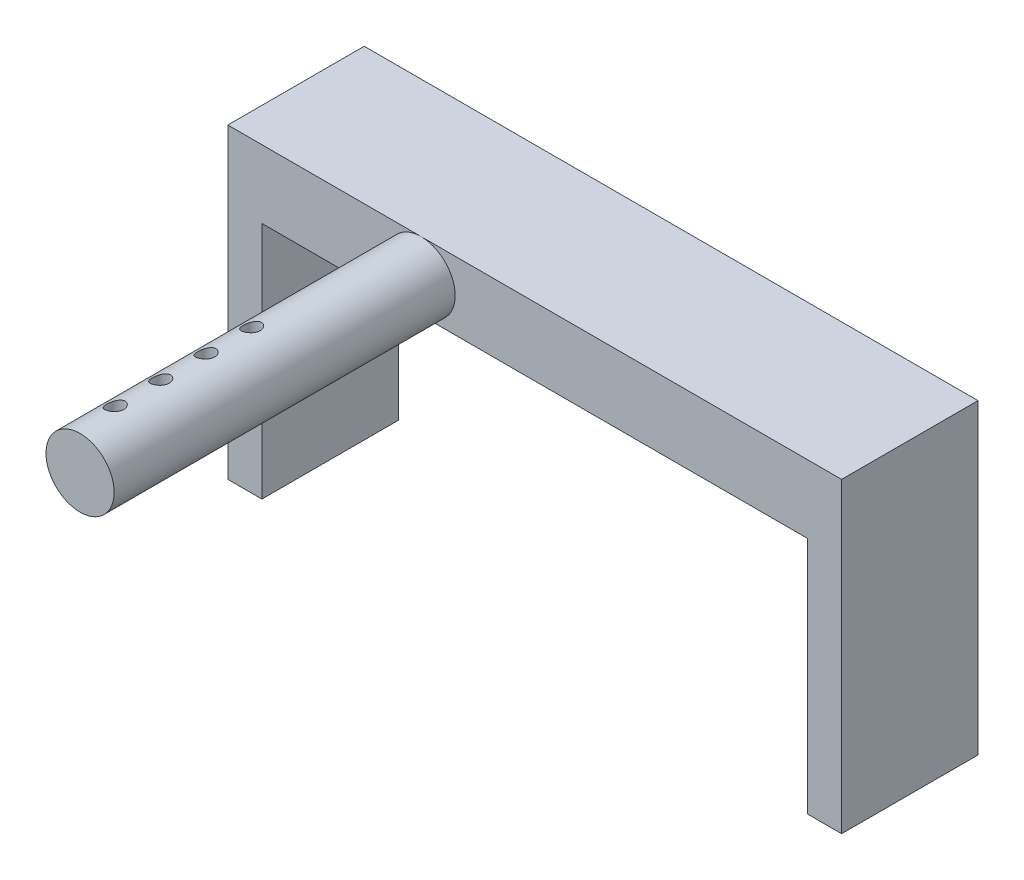
from build123d import *

# Parameters (mm, degrees)
BOSS_EXTRUDE1_DEPTH = 12
SKETCH2_R           = 3
BOSS_EXTRUDE2_DEPTH = 30
CUT_EXTRUDE1_REACH  = 29
SKETCH3_R           = 0.75
SKETCH4_R           = 1.45
CUT_EXTRUDE2_DEPTH  = 5


with BuildPart() as part:
    # Sketch1 → Boss-Extrude1 (new body)
    with BuildSketch(Plane.XY):
        Polygon((0, 0), (0, 27), (54, 27), (54, 0), (51, 0), (51, 21), (3, 21), (3, 0), align=None)
    extrude(amount=BOSS_EXTRUDE1_DEPTH)

    # Sketch2 → Boss-Extrude2 (add)
    with BuildSketch(Plane.XY.offset(12)):
        with Locations((17, 24)):
            Circle(SKETCH2_R)
    extrude(amount=BOSS_EXTRUDE2_DEPTH)

    # Sketch3 → Cut-Extrude1 (cut, up to next)
    with BuildSketch(Plane(origin=(0, 27, 0), x_dir=(1, 0, 0), z_dir=(0, 1, 0)), mode=Mode.PRIVATE) as cut_extrude1_sk1:
        with Locations((16.346450023, -38.25)):
            Circle(SKETCH3_R)
    cut_extrude1_tool1 = extrude(cut_extrude1_sk1.sketch, amount=-CUT_EXTRUDE1_REACH, mode=Mode.PRIVATE) & part.part
    add(cut_extrude1_tool1.solids().sort_by_distance((16.34645, 27, 38.25))[0], mode=Mode.SUBTRACT)
    # Sketch3 → Cut-Extrude1 (cut, up to next)
    with BuildSketch(Plane(origin=(0, 27, 0), x_dir=(1, 0, 0), z_dir=(0, 1, 0)), mode=Mode.PRIVATE) as cut_extrude1_sk2:
        with Locations((16.346450023, -34.25)):
            Circle(SKETCH3_R)
    cut_extrude1_tool2 = extrude(cut_extrude1_sk2.sketch, amount=-CUT_EXTRUDE1_REACH, mode=Mode.PRIVATE) & part.part
    add(cut_extrude1_tool2.solids().sort_by_distance((16.34645, 27, 34.25))[0], mode=Mode.SUBTRACT)
    # Sketch3 → Cut-Extrude1 (cut, up to next)
    with BuildSketch(Plane(origin=(0, 27, 0), x_dir=(1, 0, 0), z_dir=(0, 1, 0)), mode=Mode.PRIVATE) as cut_extrude1_sk3:
        with Locations((16.346450023, -30.25)):
            Circle(SKETCH3_R)
    cut_extrude1_tool3 = extrude(cut_extrude1_sk3.sketch, amount=-CUT_EXTRUDE1_REACH, mode=Mode.PRIVATE) & part.part
    add(cut_extrude1_tool3.solids().sort_by_distance((16.34645, 27, 30.25))[0], mode=Mode.SUBTRACT)
    # Sketch3 → Cut-Extrude1 (cut, up to next)
    with BuildSketch(Plane(origin=(0, 27, 0), x_dir=(1, 0, 0), z_dir=(0, 1, 0)), mode=Mode.PRIVATE) as cut_extrude1_sk4:
        with Locations((16.346450023, -26.25)):
            Circle(SKETCH3_R)
    cut_extrude1_tool4 = extrude(cut_extrude1_sk4.sketch, amount=-CUT_EXTRUDE1_REACH, mode=Mode.PRIVATE) & part.part
    add(cut_extrude1_tool4.solids().sort_by_distance((16.34645, 27, 26.25))[0], mode=Mode.SUBTRACT)

    # Sketch4 → Cut-Extrude2 (cut)
    with BuildSketch(Plane(origin=(0, 0, 0), x_dir=(-1, 0, 0), z_dir=(0, 0, -1))):
        with Locations((-37, 23.816903441)):
            Circle(SKETCH4_R)
        with Locations((-17, 23.816903441)):
            Circle(SKETCH4_R)
    extrude(amount=-CUT_EXTRUDE2_DEPTH, mode=Mode.SUBTRACT)


solid = part.part
